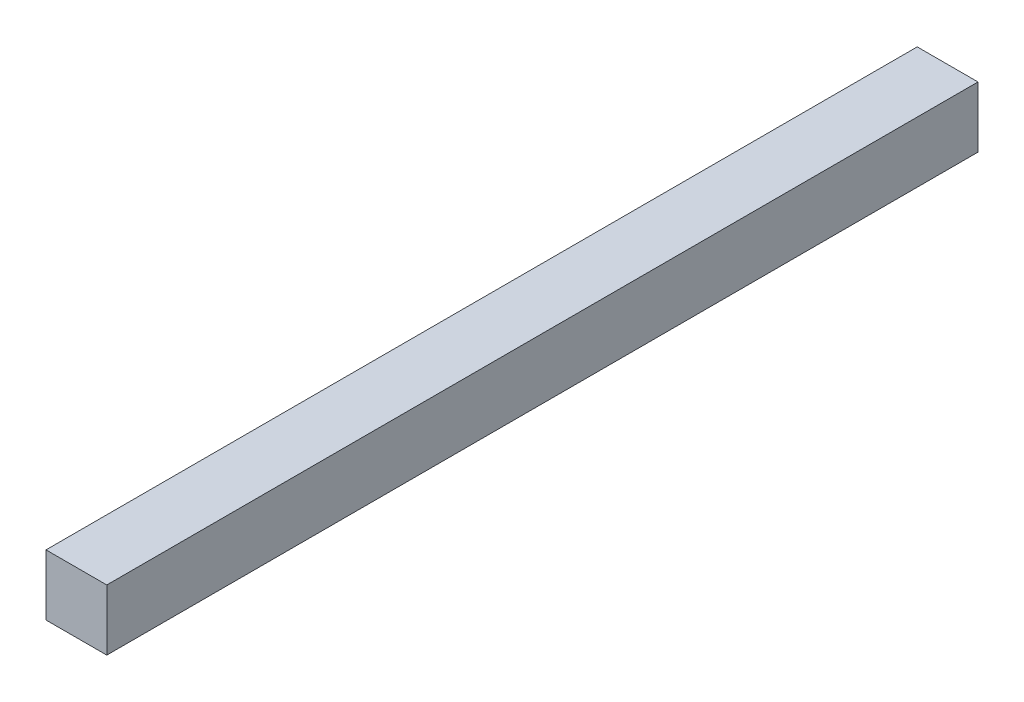
from build123d import *

# Parameters (mm, degrees)
ESQUISSE1_W      = 18
ESQUISSE1_H      = 18
EXTRUSION1_DEPTH = 258


with BuildPart() as part:
    # Esquisse1 → Extrusion1 (new body)
    with BuildSketch(Plane.XY):
        with Locations((9, 9)):
            Rectangle(ESQUISSE1_W, ESQUISSE1_H)
    extrude(amount=-EXTRUSION1_DEPTH)


solid = part.part
